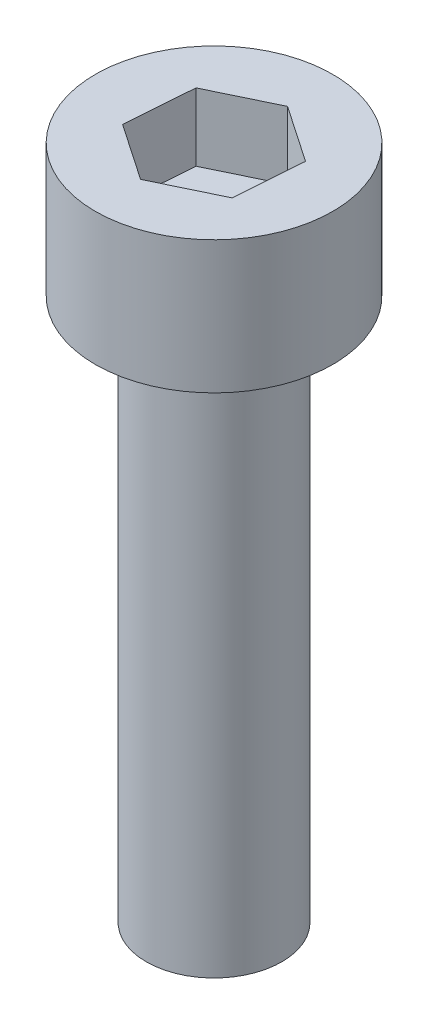
from build123d import *

# Parameters (mm, degrees)
SKETCH_1_R          = 2
EXTRUDE_1_DEPTH     = 16
SKETCH_2_R          = 3.5
EXTRUDE_2_DEPTH     = 3.91
CUT_EXTRUDE_1_DEPTH = 2


with BuildPart() as part:
    # 草图1 → 凸台-拉伸1 (new body)
    with BuildSketch(Plane(origin=(0, 0, 0), x_dir=(1, 0, 0), z_dir=(0, 1, 0))):
        Circle(SKETCH_1_R)
    extrude(amount=EXTRUDE_1_DEPTH)

    # 草图2 → 凸台-拉伸2 (add)
    with BuildSketch(Plane(origin=(0, 16, 0), x_dir=(1, 0, 0), z_dir=(0, 1, 0))):
        Circle(SKETCH_2_R)
    extrude(amount=EXTRUDE_2_DEPTH)

    # 草图3 → 切除-拉伸1 (cut)
    with BuildSketch(Plane(origin=(0, 19.91, 0), x_dir=(1, 0, 0), z_dir=(0, 1, 0))):
        Polygon((1.669374847, -1.13864874), (1.820786158, 0.876396656), (0.151411311, 2.015045396), (-1.669374847, 1.13864874), (-1.820786158, -0.876396656), (-0.151411311, -2.015045396), align=None)
    extrude(amount=-CUT_EXTRUDE_1_DEPTH, mode=Mode.SUBTRACT)


solid = part.part
